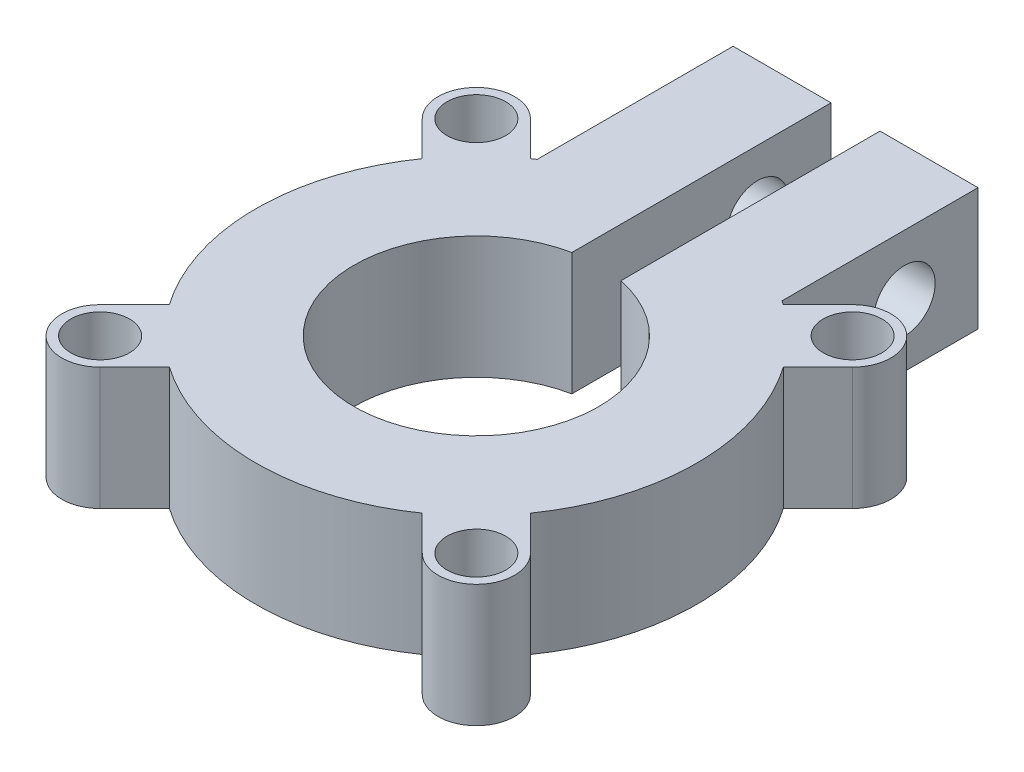
from build123d import *

# Parameters (mm, degrees)
SKETCH1_R                                  = 3.175
BOSS_EXTRUDE1_DEPTH                        = 3.175
SKETCH3_W                                  = 1.27
SKETCH3_H                                  = 6.721052908
CUT_EXTRUDE1_DEPTH                         = 3.175
SKETCH4_R                                  = 0.79375
CUT_EXTRUDE2_DEPTH                         = 9.89
SKETCH5_R                                  = 0.762
BOSS_EXTRUDE2_DEPTH                        = 3.175
MIRROR1_AT_THE_SECOND_PLANE_COPY_1_SKETC_R = 0.762
MIRROR1_AT_THE_SECOND_PLANE_COPY_1_DEPTH   = 3.175


with BuildPart() as part:
    # Sketch1 → Boss-Extrude1 (new body)
    with BuildSketch(Plane(origin=(0, 0, 0), x_dir=(1, 0, 0), z_dir=(0, 1, 0))):
        with BuildLine():
            Line((3.175, 4.751904881), (3.175, 9.831904881))
            Line((3.175, 9.831904881), (-3.175, 9.831904881))
            Line((-3.175, 9.831904881), (-3.175, 4.751904881))
            ThreePointArc((-3.175, 4.751904881), (0, -5.715), (3.175, 4.751904881))
        make_face()
        Circle(SKETCH1_R, mode=Mode.SUBTRACT)
    extrude(amount=BOSS_EXTRUDE1_DEPTH)

    # Sketch3 → Cut-Extrude1 (cut)
    with BuildSketch(Plane(origin=(0, 3.175, 0), x_dir=(1, 0, 0), z_dir=(0, 1, 0))):
        with Locations((0, 6.471378427)):
            Rectangle(SKETCH3_W, SKETCH3_H)
    extrude(amount=-CUT_EXTRUDE1_DEPTH, mode=Mode.SUBTRACT)

    # Sketch4 → Cut-Extrude2 (cut, through all)
    with BuildSketch(Plane(origin=(3.175, 0, 0), x_dir=(0, 0, -1), z_dir=(1, 0, 0))):
        with Locations((7.926904881, 1.5875)):
            Circle(SKETCH4_R)
    extrude(amount=-CUT_EXTRUDE2_DEPTH, mode=Mode.SUBTRACT)

    # Sketch5 → Boss-Extrude2 (add)
    with BuildSketch(Plane.XZ):
        with BuildLine():
            Line((-4.176191145, -5.579356164), (-3.278165533, -4.681330552))
            ThreePointArc((-3.278165533, -4.681330552), (-4.041115254, -4.041115254), (-4.681330552, -3.278165533))
            Line((-4.681330552, -3.278165533), (-5.579356164, -4.176191145))
            ThreePointArc((-5.579356164, -4.176191145), (-5.579356164, -5.579356164), (-4.176191145, -5.579356164))
        make_face()
        with Locations((-4.877773655, -4.877773655)):
            Circle(SKETCH5_R, mode=Mode.SUBTRACT)
    boss_extrude2 = extrude(amount=-BOSS_EXTRUDE2_DEPTH)

    # Mirror1: Boss-Extrude2 across plane
    add(boss_extrude2.mirror(Plane(origin=(0, 0, 0), x_dir=(0, 0, 1), z_dir=(1, 0, 0))))

    # Mirror1 at the second plane: Boss-Extrude2 across plane
    add(boss_extrude2.mirror(Plane.XY))

    # Mirror1 at the second plane copy 1 sketc → Mirror1 at the second plane copy 1 (add)
    with BuildSketch(Plane(origin=(0, 0, 0), x_dir=(-1, 0, 0), z_dir=(0, -1, 0))):
        with BuildLine():
            Line((-4.176191145, -5.579356164), (-3.278165533, -4.681330552))
            ThreePointArc((-3.278165533, -4.681330552), (-4.041115254, -4.041115254), (-4.681330552, -3.278165533))
            Line((-4.681330552, -3.278165533), (-5.579356164, -4.176191145))
            ThreePointArc((-5.579356164, -4.176191145), (-5.579356164, -5.579356164), (-4.176191145, -5.579356164))
        make_face()
        with Locations((-4.877773655, -4.877773655)):
            Circle(MIRROR1_AT_THE_SECOND_PLANE_COPY_1_SKETC_R, mode=Mode.SUBTRACT)
    extrude(amount=-MIRROR1_AT_THE_SECOND_PLANE_COPY_1_DEPTH)


solid = part.part
